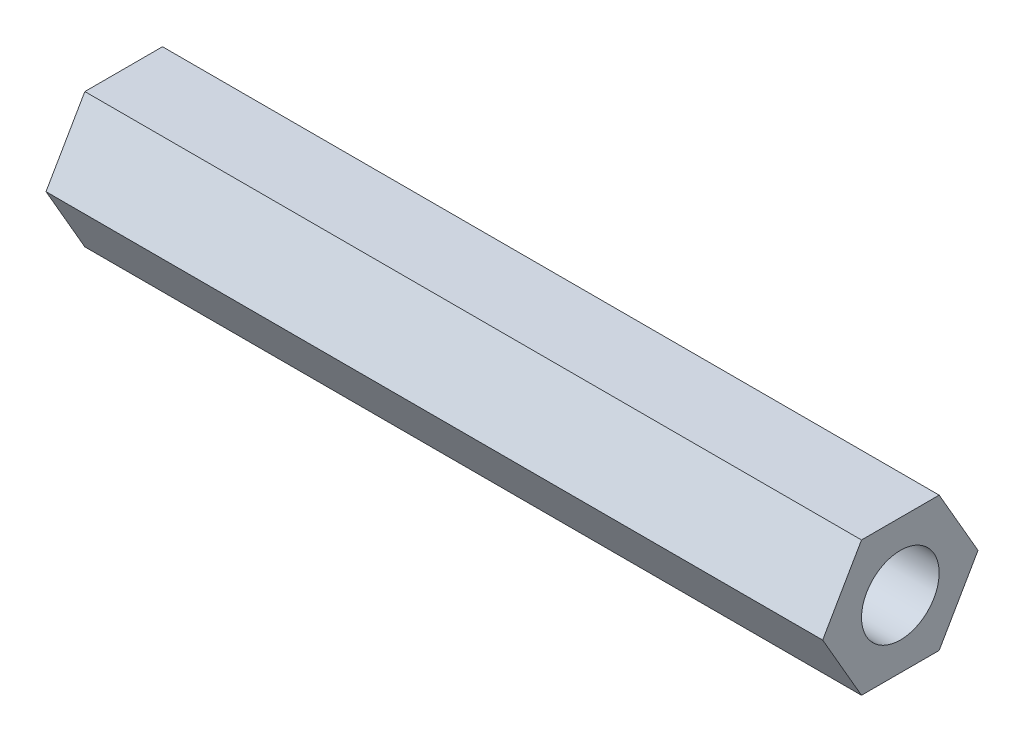
from build123d import *

# Parameters (mm, degrees)
BOSS_EXTRUDE1_DEPTH = 63.5
SKETCH2_R           = 3.175
CUT_EXTRUDE1_DEPTH  = 64.5


with BuildPart() as part:
    # Sketch1 → Boss-Extrude1 (new body)
    with BuildSketch(Plane(origin=(0, 0, 0), x_dir=(0, 0, -1), z_dir=(1, 0, 0))):
        Polygon((6.35, -1.3864e-05), (3.175012007, 5.499254382), (-3.174987993, 5.499268246), (-6.35, 1.3864e-05), (-3.175012007, -5.499254382), (3.174987993, -5.499268246), align=None)
    extrude(amount=BOSS_EXTRUDE1_DEPTH)

    # Sketch2 → Cut-Extrude1 (cut, through all)
    with BuildSketch(Plane.ZY):
        Circle(SKETCH2_R)
    extrude(amount=-CUT_EXTRUDE1_DEPTH, mode=Mode.SUBTRACT)


solid = part.part
